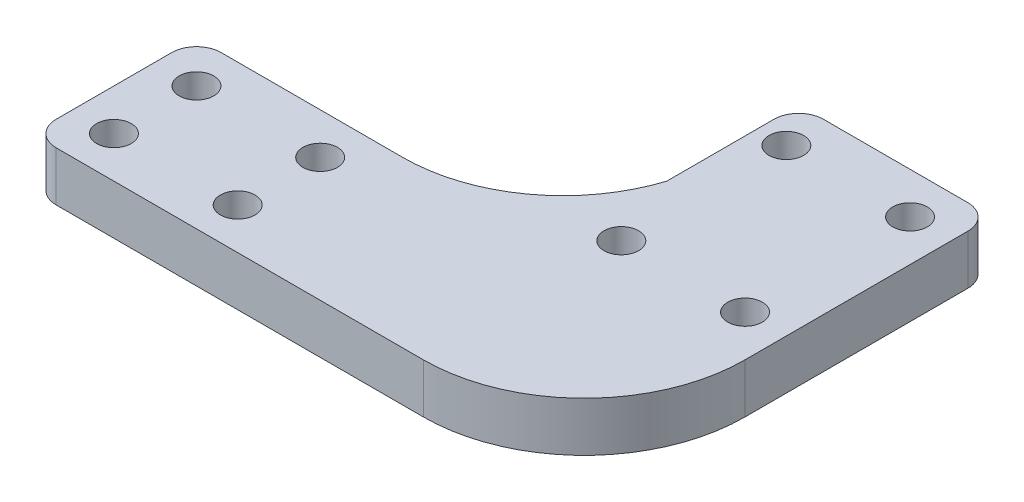
from build123d import *

# Parameters (mm, degrees)
SKETCH_1_R      = 2.1
EXTRUDE_1_DEPTH = 6
FILLET_1_R      = 3


with BuildPart() as part:
    # 草图1 → 凸台-拉伸1 (new body)
    with BuildSketch(Plane(origin=(0, 0, 0), x_dir=(1, 0, 0), z_dir=(0, 1, 0))):
        with BuildLine():
            Line((-11, 15), (12.5, 15))
            Line((12.5, 15), (12.5, -15))
            ThreePointArc((12.5, -15), (6.788582233, -28.788582233), (-7, -34.5))
            Line((-7, -34.5), (-54.5, -34.5))
            Line((-54.5, -34.5), (-54.5, -14.5))
            Line((-54.5, -14.5), (-29.5, -14.5))
            ThreePointArc((-29.5, -14.5), (-18.049017509, -10.766161191), (-11, -1))
            Line((-11, -1), (-11, 15))
        make_face()
        with Locations((-49.5, -19.5)):
            Circle(SKETCH_1_R, mode=Mode.SUBTRACT)
        with Locations((-7.5, -10)):
            Circle(SKETCH_1_R, mode=Mode.SUBTRACT)
        with Locations((-34.5, -19.5)):
            Circle(SKETCH_1_R, mode=Mode.SUBTRACT)
        with Locations((-34.5, -29.5)):
            Circle(SKETCH_1_R, mode=Mode.SUBTRACT)
        with Locations((-49.5, -29.5)):
            Circle(SKETCH_1_R, mode=Mode.SUBTRACT)
        with Locations((7.5, -10)):
            Circle(SKETCH_1_R, mode=Mode.SUBTRACT)
        with Locations((7.5, 10)):
            Circle(SKETCH_1_R, mode=Mode.SUBTRACT)
        with Locations((-7.5, 10)):
            Circle(SKETCH_1_R, mode=Mode.SUBTRACT)
    extrude(amount=EXTRUDE_1_DEPTH)

    # 圆角1
    fillet_1_edges = [part.edges().sort_by_distance(p)[0] for p in [
        (-11, 3, -15),
        (12.5, 3, -15),
        (-54.5, 3, 34.5),
        (-54.5, 3, 14.5),
    ]]
    fillet(fillet_1_edges, radius=FILLET_1_R)


solid = part.part
